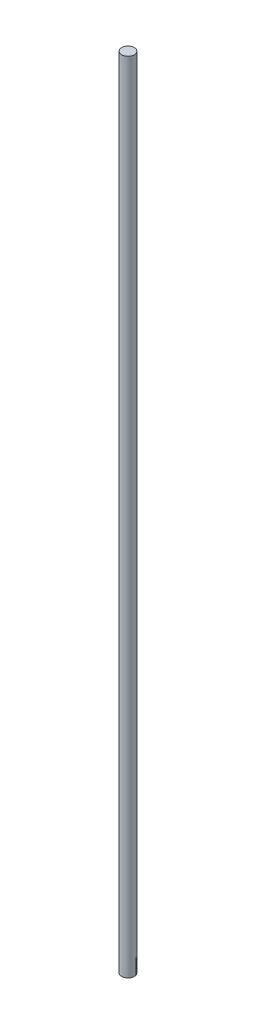
from build123d import *

# Parameters (mm, degrees)
AUFSATZ_LINEAR_START            = 237
SKIZZE3_R                       = 3
AUFSATZ_LINEAR_AUSTRAGEN1_DEPTH = 381
SCHNITT_LINEAR_START            = 237
SKIZZE4_R                       = 1.25
SCHNITT_LINEAR_AUSTRAGEN1_DEPTH = 20


with BuildPart() as part:
    # Skizze3 → Aufsatz-Linear austragen1 (new body)
    with BuildSketch(Plane(origin=(0, 0, 0), x_dir=(1, 0, 0), z_dir=(0, 1, 0)).offset(AUFSATZ_LINEAR_START)):
        with Locations((14, 0)):
            Circle(SKIZZE3_R)
    extrude(amount=AUFSATZ_LINEAR_AUSTRAGEN1_DEPTH)

    # Skizze4 → Schnitt-Linear austragen1 (cut)
    with BuildSketch(Plane(origin=(0, 0, 0), x_dir=(1, 0, 0), z_dir=(0, 1, 0)).offset(SCHNITT_LINEAR_START)):
        with Locations((14, 0)):
            Circle(SKIZZE4_R)
    extrude(amount=SCHNITT_LINEAR_AUSTRAGEN1_DEPTH, mode=Mode.SUBTRACT)


solid = part.part
